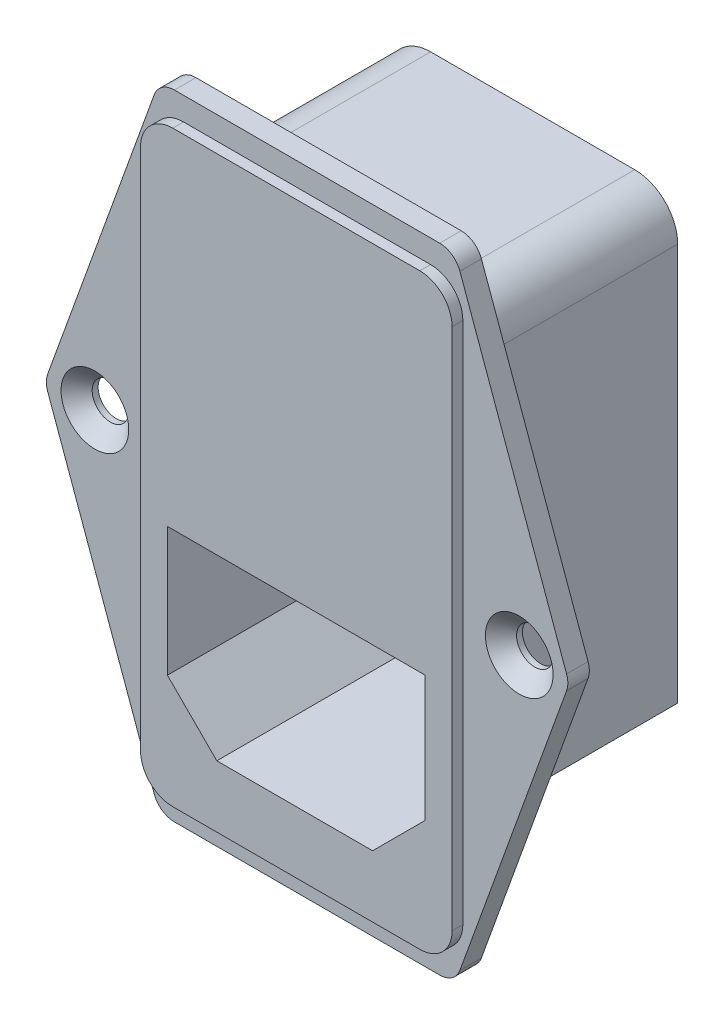
from build123d import *

# Parameters (mm, degrees)
BOSS_EXTRUDE1_DEPTH                            = 2
SKETCH2_W                                      = 29
SKETCH2_H                                      = 54.7
BOSS_EXTRUDE2_DEPTH                            = 1
FILLET1_R                                      = 3
FILLET2_R                                      = 2
CSK_FOR_M3_FLAT_HEAD_MACHINE_SCREW1_AT_2_COUNT = 2
CSK_FOR_M3_FLAT_HEAD_MACHINE_SCREW1_AT_2_PITCH = 39.5
SKETCH5_W                                      = 27
SKETCH5_H                                      = 47
BOSS_EXTRUDE3_DEPTH                            = 19
CHAMFER1_SIZE                                  = 6
FILLET3_R                                      = 4
CUT_EXTRUDE1_DEPTH                             = 17


with BuildPart() as part:
    # Sketch1 → Boss-Extrude1 (new body)
    with BuildSketch(Plane.XY):
        Polygon((-13.75, 29.5), (-24.4, 0), (-13.75, -29.5), (13.75, -29.5), (24.4, 0), (13.75, 29.5), align=None)
    extrude(amount=BOSS_EXTRUDE1_DEPTH)

    # Sketch2 → Boss-Extrude2 (add)
    with BuildSketch(Plane.XY.offset(2)):
        Rectangle(SKETCH2_W, SKETCH2_H)
    extrude(amount=BOSS_EXTRUDE2_DEPTH)

    # Fillet1
    fillet1_edges = [part.edges().sort_by_distance(p)[0] for p in [
        (14.5, -27.35, 2.5),
        (14.5, 27.35, 2.5),
        (-14.5, 27.35, 2.5),
        (-14.5, -27.35, 2.5),
    ]]
    fillet(fillet1_edges, radius=FILLET1_R)

    # Fillet2
    fillet2_edges = [part.edges().sort_by_distance(p)[0] for p in [
        (24.4, 0, 1),
        (13.75, -29.5, 1),
        (-13.75, -29.5, 1),
        (-24.4, 0, 1),
        (-13.75, 29.5, 1),
        (13.75, 29.5, 1),
    ]]
    fillet(fillet2_edges, radius=FILLET2_R)

    # Sketch3 → CSK for M3 Flat Head Machine Screw1 (revolve, cut)
    with BuildSketch(Plane(origin=(-19.75, 0, 2), x_dir=(0, -1, 0), z_dir=(1, 0, 0))):
        Polygon((0, 0), (0, 2), (1.7, 2), (1.7, 1.45), (3.15, 0), align=None)
    csk_for_m3_flat_head_machine_screw1 = revolve(axis=Axis((-19.75, 0, 8.35), (0, 0, -1)), mode=Mode.SUBTRACT)

    # CSK for M3 Flat Head Machine Screw1 at 2: CSK for M3 Flat Head Machine Screw1 ×2
    with Locations(*[(i * CSK_FOR_M3_FLAT_HEAD_MACHINE_SCREW1_AT_2_PITCH, 0, 0) for i in range(1, CSK_FOR_M3_FLAT_HEAD_MACHINE_SCREW1_AT_2_COUNT)]):
        add(csk_for_m3_flat_head_machine_screw1, mode=Mode.SUBTRACT)

    # Sketch5 → Boss-Extrude3 (add)
    with BuildSketch(Plane(origin=(0, 0, 0), x_dir=(-1, 0, 0), z_dir=(0, 0, -1))):
        Rectangle(SKETCH5_W, SKETCH5_H)
    extrude(amount=BOSS_EXTRUDE3_DEPTH)

    # Chamfer1
    chamfer1_edges = [part.edges().sort_by_distance(p)[0] for p in [
        (-13.5, -23.5, -9.5),
        (13.5, -23.5, -9.5),
    ]]
    chamfer(chamfer1_edges, length=CHAMFER1_SIZE)

    # Fillet3
    fillet3_edges = [part.edges().sort_by_distance(p)[0] for p in [
        (-13.5, 23.5, -9.5),
        (13.5, 23.5, -9.5),
    ]]
    fillet(fillet3_edges, radius=FILLET3_R)

    # Sketch6 → Cut-Extrude1 (cut)
    with BuildSketch(Plane.XY.offset(3)):
        Polygon((-12, -5), (12, -5), (12, -16.7), (7.1, -21.6), (-7.4, -21.6), (-12, -17), align=None)
    extrude(amount=-CUT_EXTRUDE1_DEPTH, mode=Mode.SUBTRACT)


solid = part.part
